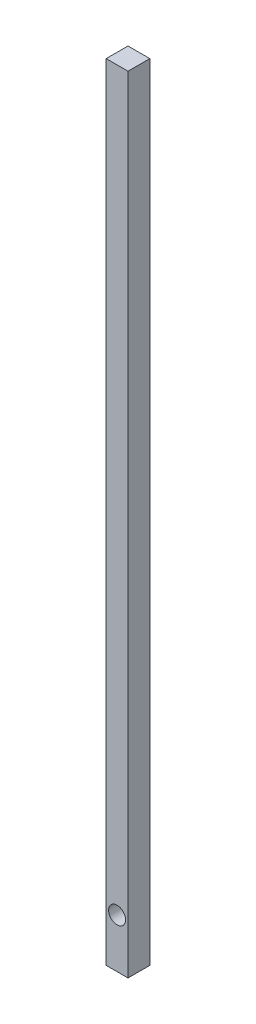
from build123d import *

# Parameters (mm, degrees)
SKETCH1_W           = 25.4
SKETCH1_H           = 25.4
BOSS_EXTRUDE2_DEPTH = 914.4
SKETCH2_R           = 9.906
CUT_EXTRUDE1_DEPTH  = 26.4


with BuildPart() as part:
    # Sketch1 → Boss-Extrude2 (new body)
    with BuildSketch(Plane(origin=(0, 0, 0), x_dir=(1, 0, 0), z_dir=(0, 1, 0))):
        Rectangle(SKETCH1_W, SKETCH1_H)
    extrude(amount=BOSS_EXTRUDE2_DEPTH)

    # Sketch2 → Cut-Extrude1 (cut, through all)
    with BuildSketch(Plane(origin=(0, 0, -12.7), x_dir=(-1, 0, 0), z_dir=(0, 0, -1))):
        with Locations((0, 57.15)):
            Circle(SKETCH2_R)
    extrude(amount=-CUT_EXTRUDE1_DEPTH, mode=Mode.SUBTRACT)


solid = part.part
